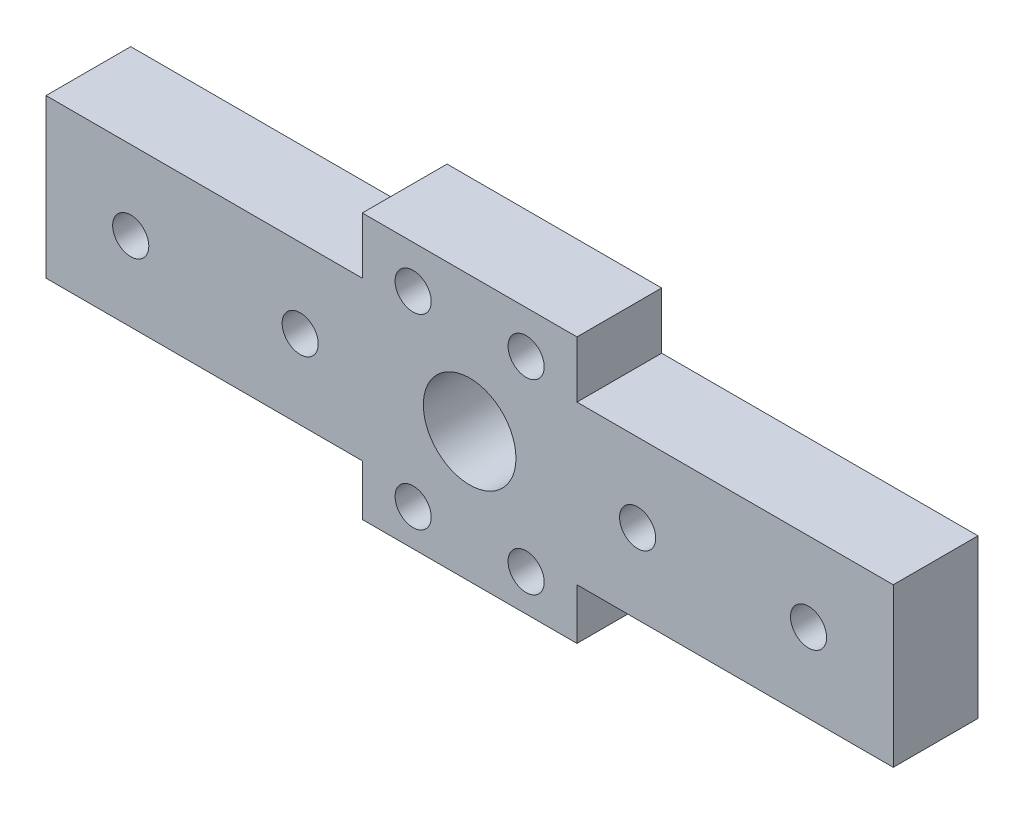
from build123d import *

# Parameters (mm, degrees)
SKETCH_1_R      = 4.1
SKETCH_1_R_2    = 1.6
EXTRUDE_1_DEPTH = 7.5


with BuildPart() as part:
    # 草图1 → 凸台-拉伸1 (new body)
    with BuildSketch(Plane.XY):
        Polygon((0, 11.5), (0, 4.5), (0.416202301, 4.5), (28, 4.5), (28, 0), (47, 0), (47, 4.5), (75, 4.5), (75, 18.5), (47, 18.5), (47, 23.5), (28, 23.5), (28, 18.5), (0, 18.5), align=None)
        with Locations((37.5, 11.5)):
            Circle(SKETCH_1_R, mode=Mode.SUBTRACT)
        with Locations((67.5, 11.5)):
            Circle(SKETCH_1_R_2, mode=Mode.SUBTRACT)
        with Locations((32.500024738, 3.227756818)):
            Circle(SKETCH_1_R_2, mode=Mode.SUBTRACT)
        with Locations((42.5, 3.25)):
            Circle(SKETCH_1_R_2, mode=Mode.SUBTRACT)
        with Locations((42.5, 19.75)):
            Circle(SKETCH_1_R_2, mode=Mode.SUBTRACT)
        with Locations((32.500024738, 19.75)):
            Circle(SKETCH_1_R_2, mode=Mode.SUBTRACT)
        with Locations((7.5, 11.5)):
            Circle(SKETCH_1_R_2, mode=Mode.SUBTRACT)
        with Locations((52.370486737, 11.554033831)):
            Circle(SKETCH_1_R_2, mode=Mode.SUBTRACT)
        with Locations((22.5, 11.5)):
            Circle(SKETCH_1_R_2, mode=Mode.SUBTRACT)
    extrude(amount=EXTRUDE_1_DEPTH)


solid = part.part
